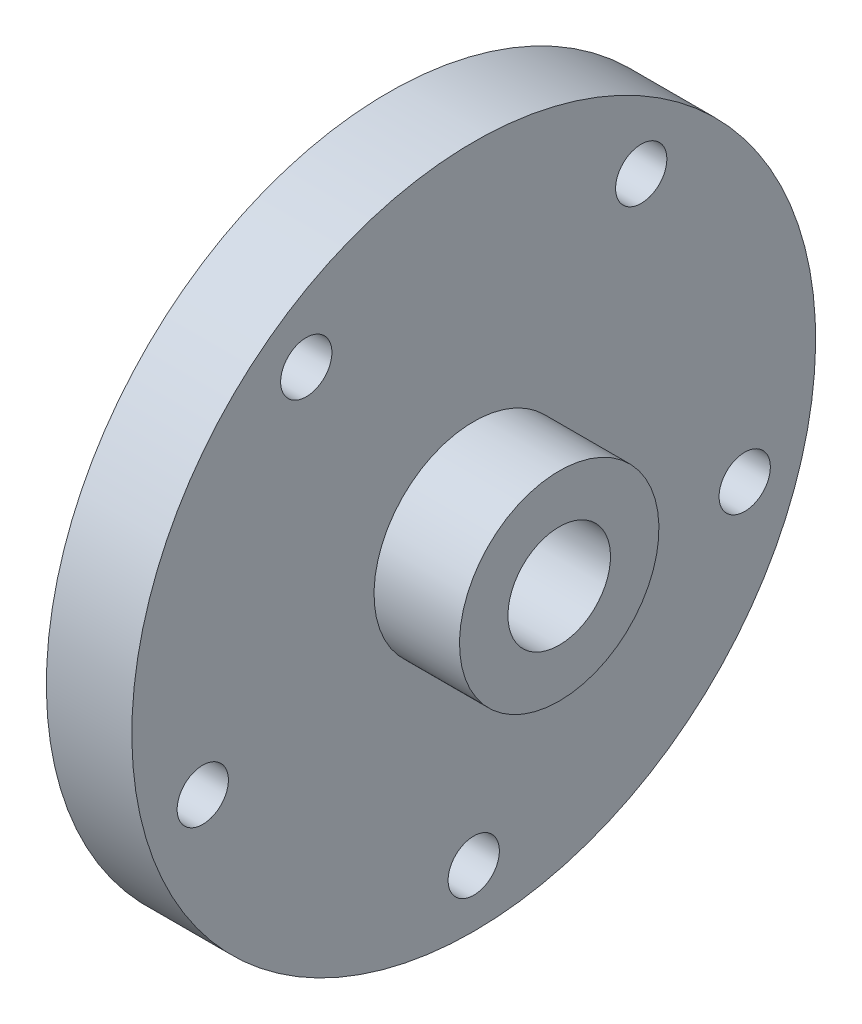
from build123d import *

# Parameters (mm, degrees)
M8_CLEARANCE_HOLE1_D     = 9
M8_CLEARANCE_HOLE1_DEPTH = 15
CIRPATTERN1_COUNT        = 5


with BuildPart() as part:
    # Sketch2 → Revolve1 (revolve)
    with BuildSketch(Plane.XY):
        Polygon((-30, 9), (0, 9), (0, 17.5), (-15, 17.5), (-15, 60), (-30, 60), (-30, 37.5), (-20, 37.5), (-20, 12.5), (-30, 12.5), align=None)
    revolve(axis=Axis((-30, 0, 0), (1, 0, 0)))

    # M8 Clearance Hole1
    with Locations(Plane(origin=(-15, -50, 0), x_dir=(0, 0, 1), z_dir=(1, 0, 0))):
        with Locations((0, 0)):
            m8_clearance_hole1 = Hole(M8_CLEARANCE_HOLE1_D / 2, depth=M8_CLEARANCE_HOLE1_DEPTH)

    # CirPattern1: M8 Clearance Hole1 ×5 about axis
    cirpattern1_axis = Axis((0, 0, 0), (1, 0, 0))
    for i in range(1, CIRPATTERN1_COUNT):
        add(m8_clearance_hole1.rotate(cirpattern1_axis, i * 360 / CIRPATTERN1_COUNT), mode=Mode.SUBTRACT)


solid = part.part
